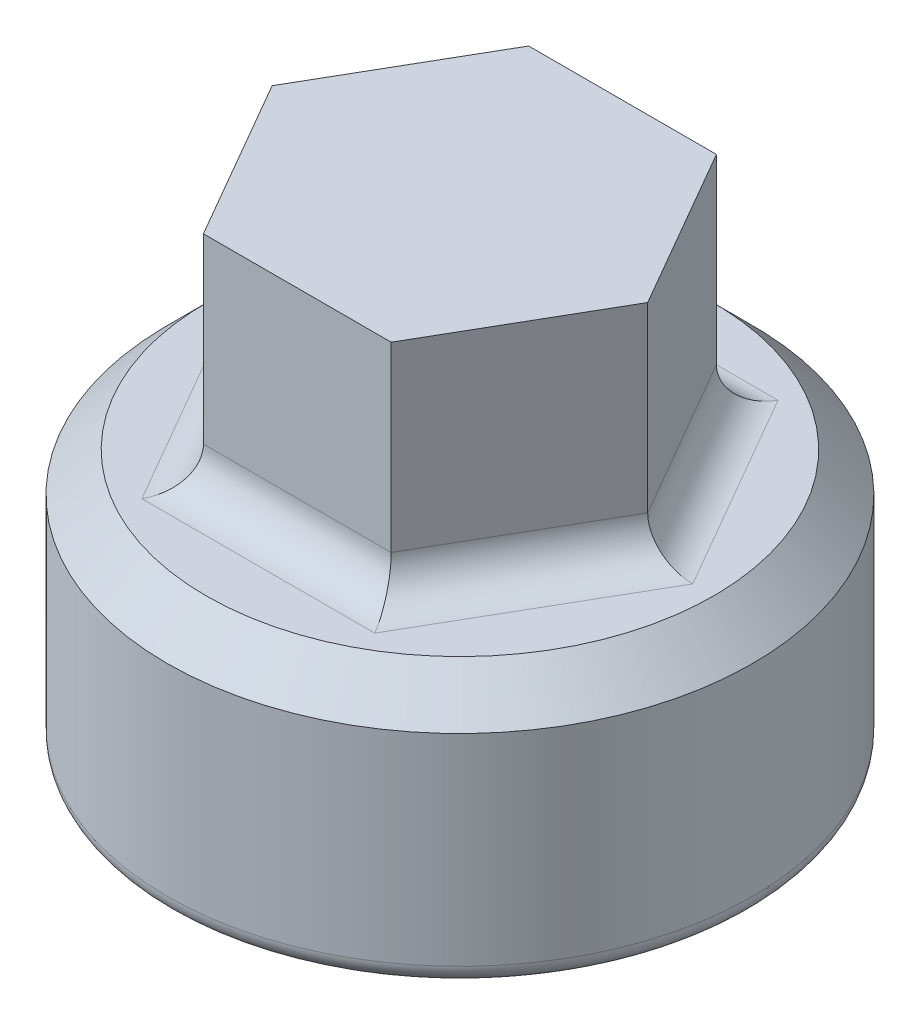
from build123d import *

# Parameters (mm, degrees)
SKETCH1_R           = 45
BOSS_EXTRUDE1_DEPTH = 34
SKETCH2_R           = 45
BOSS_EXTRUDE2_DEPTH = 6
BOSS_EXTRUDE3_DEPTH = 34
FILLET1_R           = 6
CHAMFER1_SIZE       = 6
FILLET2_R           = 3
FILLET3_R           = 6.35
SKETCH4_R           = 3.175
CUT_EXTRUDE1_DEPTH  = 34


with BuildPart() as part:
    # Sketch1 → Boss-Extrude1 (new body)
    with BuildSketch(Plane(origin=(0, 0, 0), x_dir=(1, 0, 0), z_dir=(0, 1, 0))):
        Circle(SKETCH1_R)
        Polygon((37.816442632, 0), (18.908221316, 32.75), (-18.908221316, 32.75), (-37.816442632, 0), (-18.908221316, -32.75), (18.908221316, -32.75), align=None, mode=Mode.SUBTRACT)
    extrude(amount=BOSS_EXTRUDE1_DEPTH)

    # Sketch2 → Boss-Extrude2 (add)
    with BuildSketch(Plane(origin=(0, 34, 0), x_dir=(1, 0, 0), z_dir=(0, 1, 0))):
        Circle(SKETCH2_R)
    extrude(amount=BOSS_EXTRUDE2_DEPTH)

    # Sketch3 → Boss-Extrude3 (add)
    with BuildSketch(Plane(origin=(0, 40, 0), x_dir=(1, 0, 0), z_dir=(0, 1, 0))):
        Polygon((28.867513459, 0), (14.43375673, 25), (-14.43375673, 25), (-28.867513459, 0), (-14.43375673, -25), (14.43375673, -25), align=None)
    extrude(amount=BOSS_EXTRUDE3_DEPTH)

    # Fillet1
    fillet1_edges = [part.edges().sort_by_distance(p)[0] for p in [
        (21.650635095, 40, 12.5),
        (21.650635095, 40, -12.5),
        (0, 40, -25),
        (-21.650635095, 40, -12.5),
        (-21.650635095, 40, 12.5),
        (0, 40, 25),
    ]]
    fillet(fillet1_edges, radius=FILLET1_R)

    # Chamfer1
    chamfer1_edges = [part.edges().sort_by_distance(p)[0] for p in [
        (-45, 40, 0),
    ]]
    chamfer(chamfer1_edges, length=CHAMFER1_SIZE)

    # Fillet2
    fillet2_edges = [part.edges().sort_by_distance(p)[0] for p in [
        (-45, 0, 0),
    ]]
    fillet(fillet2_edges, radius=FILLET2_R)

    # Fillet3
    fillet3_edges = [part.edges().sort_by_distance(p)[0] for p in [
        (37.816442632, 17, 0),
        (18.908221316, 17, -32.75),
        (-18.908221316, 17, -32.75),
        (-37.816442632, 17, 0),
        (-18.908221316, 17, 32.75),
        (18.908221316, 17, 32.75),
    ]]
    fillet(fillet3_edges, radius=FILLET3_R)

    # Sketch4 → Cut-Extrude1 (cut)
    with BuildSketch(Plane.XZ):
        with Locations((17.320721316, 30.000369343)):
            Circle(SKETCH4_R)
        with Locations((34.641442632, 0)):
            Circle(SKETCH4_R)
        with Locations((17.320721316, -30.000369343)):
            Circle(SKETCH4_R)
        with Locations((-17.320721316, -30.000369343)):
            Circle(SKETCH4_R)
        with Locations((-34.641442632, 0)):
            Circle(SKETCH4_R)
        with Locations((-17.320721316, 30.000369343)):
            Circle(SKETCH4_R)
    extrude(amount=-CUT_EXTRUDE1_DEPTH, mode=Mode.SUBTRACT)


solid = part.part
